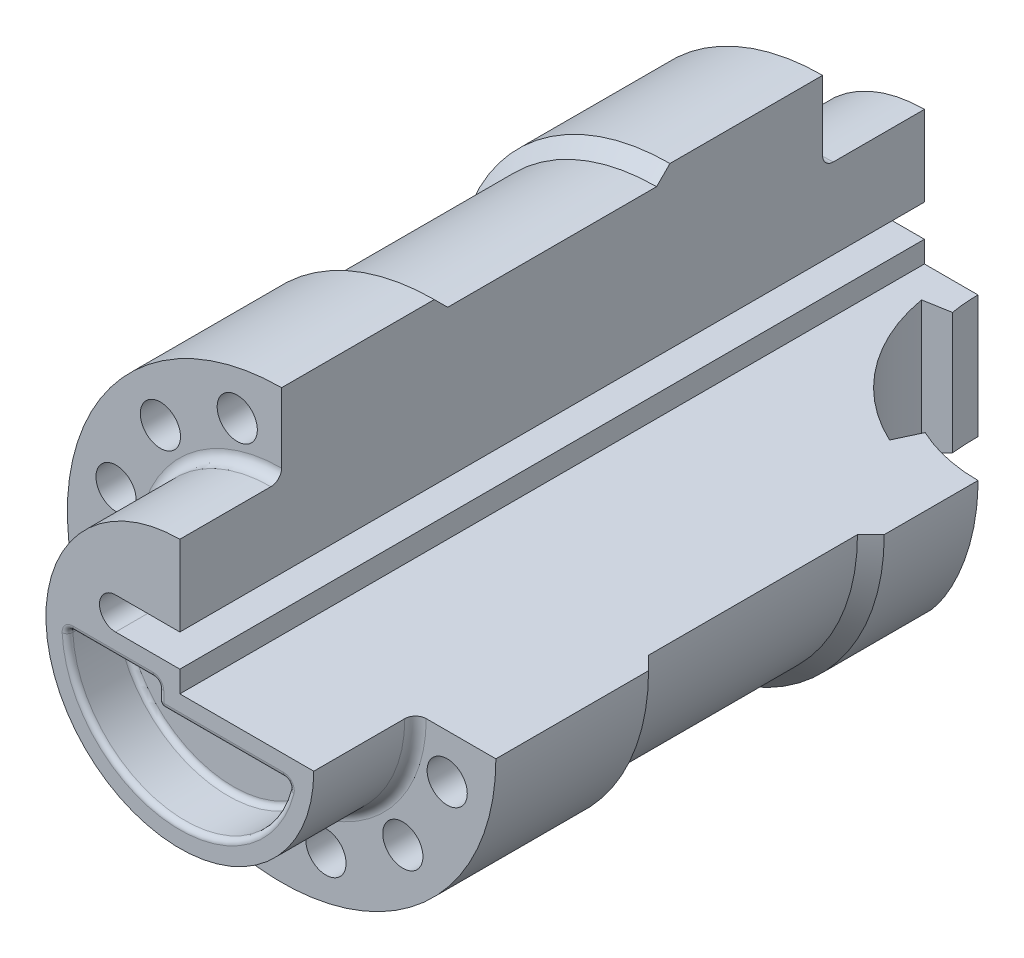
from build123d import *

# Parameters (mm, degrees)
BOSS_EXTRUDE7_DEPTH = 139
CUT_EXTRUDE1_DEPTH  = 19
CUT_EXTRUDE2_DEPTH  = 19
FILLET5_R           = 2
FILLET6_R           = 2
SKETCH11_R          = 3.75
CUT_EXTRUDE3_DEPTH  = 121
CUT_EXTRUDE4_DEPTH  = 41
CUT_EXTRUDE5_DEPTH  = 10
FILLET7_R           = 1


with BuildPart() as part:
    # Sketch1 → Boss-Extrude7 (new body)
    with BuildSketch(Plane.XY):
        with BuildLine():
            Line((0, 10), (0, 40))
            ThreePointArc((0, 40), (-28.284271247, -28.284271247), (40, 0))
            Line((40, 0), (0, 0))
            Line((0, 0), (0, 4))
            Line((0, 4), (-12, 4))
            ThreePointArc((-12, 4), (-15, 7), (-12, 10))
            Line((-12, 10), (0, 10))
        make_face()
    extrude(amount=BOSS_EXTRUDE7_DEPTH)

    # Sketch8 → Cut-Extrude1 (cut)
    with BuildSketch(Plane.XY.offset(139)):
        with BuildLine():
            Line((25, 0), (40, 0))
            ThreePointArc((40, 0), (-28.284271247, -28.284271247), (0, 40))
            Line((0, 40), (0, 25))
            ThreePointArc((0, 25), (-17.67766953, -17.67766953), (25, 0))
        make_face()
    extrude(amount=-CUT_EXTRUDE1_DEPTH, mode=Mode.SUBTRACT)

    # Sketch9 → Cut-Extrude2 (cut)
    with BuildSketch(Plane(origin=(0, 0, 0), x_dir=(-1, 0, 0), z_dir=(0, 0, -1))):
        with BuildLine():
            Line((-25, 0), (-40, 0))
            ThreePointArc((-40, 0), (28.284271247, -28.284271247), (0, 40))
            Line((0, 40), (0, 25))
            ThreePointArc((0, 25), (17.67766953, -17.67766953), (-25, 0))
        make_face()
    extrude(amount=-CUT_EXTRUDE2_DEPTH, mode=Mode.SUBTRACT)

    # Fillet5
    fillet5_edges = [part.edges().sort_by_distance(p)[0] for p in [
        (-17.67766953, -17.67766953, 120),
    ]]
    fillet(fillet5_edges, radius=FILLET5_R)

    # Fillet6
    fillet6_edges = [part.edges().sort_by_distance(p)[0] for p in [
        (-17.67766953, -17.67766953, 19),
    ]]
    fillet(fillet6_edges, radius=FILLET6_R)

    # Sketch10 → Cut-Revolve6 (revolve, cut)
    with BuildSketch(Plane(origin=(0, 0, 0), x_dir=(0, 0, -1), z_dir=(1, 0, 0))):
        Polygon((-47.5, 40), (-50, 37.5), (-89, 37.5), (-91.5, 40), align=None)
    revolve(axis=Axis((0, 0, 139), (0, 0, -1)), mode=Mode.SUBTRACT)

    # Sketch11 → Cut-Extrude3 (cut, through all)
    with BuildSketch(Plane.XY.offset(120)):
        with Locations((-8.282209443, 30.909626441)):
            Circle(SKETCH11_R)
        with Locations((30.909626441, -8.282209443)):
            Circle(SKETCH11_R)
        with Locations((22.627416998, -22.627416998)):
            Circle(SKETCH11_R)
        with Locations((8.282209443, -30.909626441)):
            Circle(SKETCH11_R)
        with Locations((-8.282209443, -30.909626441)):
            Circle(SKETCH11_R)
        with Locations((-22.627416998, -22.627416998)):
            Circle(SKETCH11_R)
        with Locations((-30.909626441, -8.282209443)):
            Circle(SKETCH11_R)
        with Locations((-30.909626441, 8.282209443)):
            Circle(SKETCH11_R)
        with Locations((-22.627416998, 22.627416998)):
            Circle(SKETCH11_R)
    extrude(amount=-CUT_EXTRUDE3_DEPTH, mode=Mode.SUBTRACT)

    # Sketch12 → Cut-Extrude4 (cut, through all)
    with BuildSketch(Plane(origin=(0, 0, 0), x_dir=(1, 0, 0), z_dir=(0, 1, 0))):
        with BuildLine():
            Line((25, -17), (25, 0))
            Line((25, 0), (10, 0))
            ThreePointArc((10, 0), (10.114159057, -2.614672282), (10.45576741, -5.20944533))
            ThreePointArc((10.45576741, -5.20944533), (16.199399791, -18.26284287), (27.321452148, -27.189233611))
            ThreePointArc((27.321452148, -27.189233611), (33.506811582, -29.288880214), (40, -30))
            Line((40, -30), (40, -19))
            Line((40, -19), (27, -19))
            ThreePointArc((27, -19), (25.585786438, -18.414213562), (25, -17))
        make_face()
        with BuildLine():
            ThreePointArc((27.321452148, -27.189233611), (16.199399791, -18.26284287), (10.45576741, -5.20944533))
            Line((10.45576741, -5.20944533), (5.531728645, -6.077686218))
            ThreePointArc((5.531728645, -6.077686218), (12.23263309, -21.306650015), (25.208360839, -31.720772546))
            Line((25.208360839, -31.720772546), (27.321452148, -27.189233611))
        make_face()
    extrude(amount=-CUT_EXTRUDE4_DEPTH, mode=Mode.SUBTRACT)

    # Sketch16 → Cut-Extrude5 (cut)
    with BuildSketch(Plane.XY.offset(139)):
        with BuildLine():
            Line((20.615528128, -4), (-4, -4))
            Line((-4, -4), (-4, 0))
            Line((-4, 0), (-21, 0))
            ThreePointArc((-21, 0), (-2.009217424, -20.903661051), (20.615528128, -4))
        make_face()
    extrude(amount=-CUT_EXTRUDE5_DEPTH, mode=Mode.SUBTRACT)

    # Fillet7
    fillet7_edges = [part.edges().sort_by_distance(p)[0] for p in [
        (-2.009217424, -20.903661051, 129),
        (20.615528128, -4, 134),
        (-12.5, 0, 129),
        (-21, 0, 134),
        (-4, -2, 129),
        (-4, 0, 134),
        (8.307764064, -4, 129),
        (-4, -4, 134),
        (-2.009217424, -20.903661051, 139),
        (8.307764064, -4, 139),
        (-4, -2, 139),
        (-12.5, 0, 139),
    ]]
    fillet(fillet7_edges, radius=FILLET7_R)


solid = part.part
